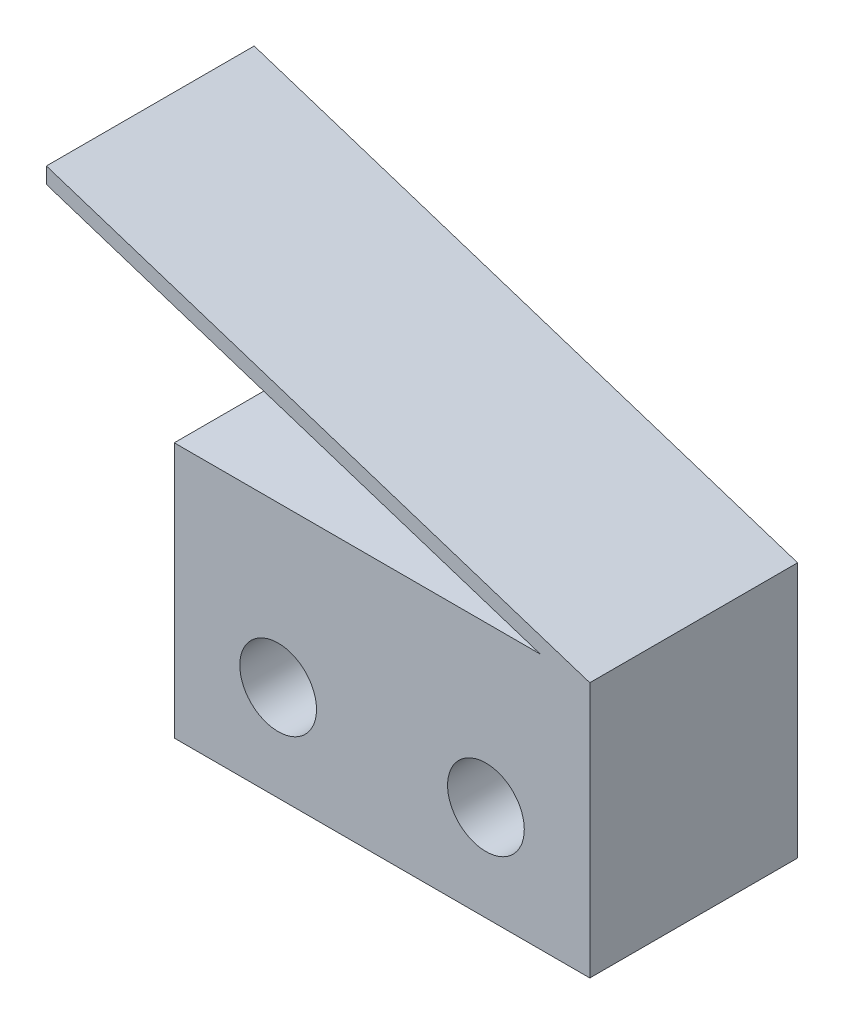
from build123d import *

# Parameters (mm, degrees)
AUFSATZ_LINEAR_AUSTRAGEN1_DEPTH = 6.5
SKIZZE2_R                       = 1.2
SCHNITT_LINEAR_AUSTRAGEN1_DEPTH = 7.5


with BuildPart() as part:
    # Skizze1 → Aufsatz-Linear austragen1 (new body)
    with BuildSketch(Plane.XY):
        Polygon((0, 0), (13, 0), (13, 8), (-4, 13.5), (-4, 13), (11.454545455, 8), (0, 8), align=None)
    extrude(amount=AUFSATZ_LINEAR_AUSTRAGEN1_DEPTH)

    # Skizze2 → Schnitt-Linear austragen1 (cut, through all)
    with BuildSketch(Plane.XY.offset(6.5)):
        with Locations((3.25, 3)):
            Circle(SKIZZE2_R)
        with Locations((9.75, 3)):
            Circle(SKIZZE2_R)
    extrude(amount=-SCHNITT_LINEAR_AUSTRAGEN1_DEPTH, mode=Mode.SUBTRACT)


solid = part.part
